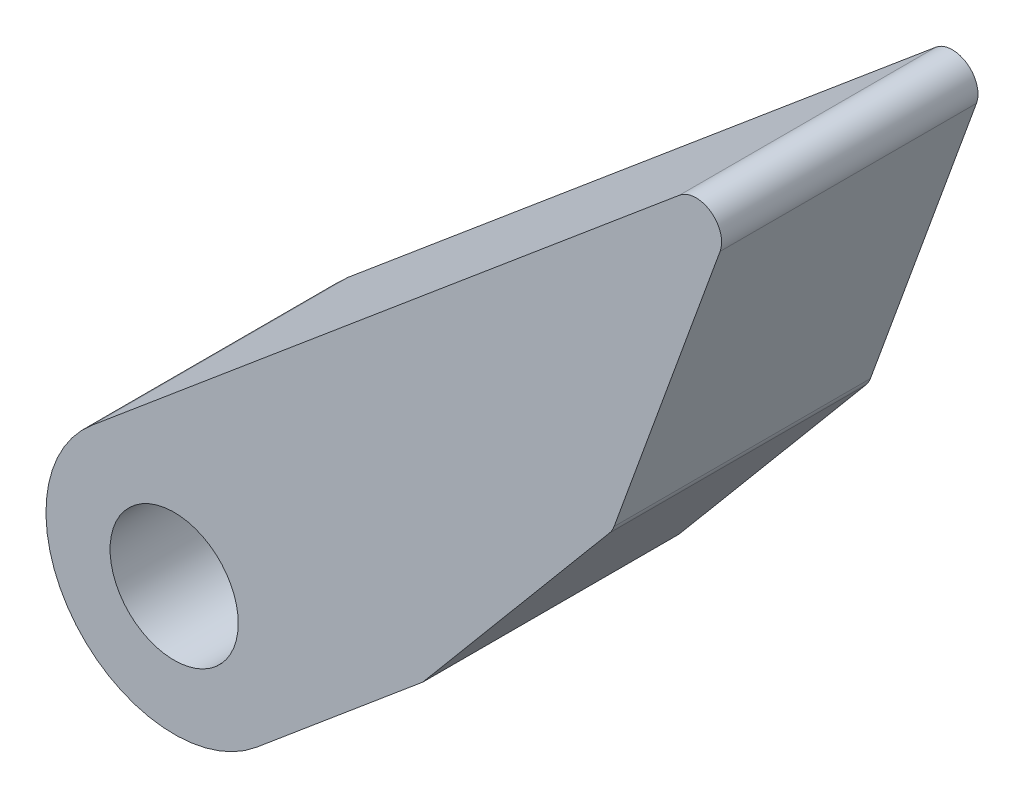
from build123d import *

# Parameters (mm, degrees)
SKETCH_1_R      = 2.5
EXTRUDE_1_DEPTH = 10


with BuildPart() as part:
    # 草圖1 → 填料-伸長1 (new body)
    with BuildSketch(Plane.XY):
        with BuildLine():
            Line((-13.71628672, 4.928383), (-17.851865082, -6.434025166))
            ThreePointArc((-17.851865082, -6.434025166), (-17.925532299, -6.592005023), (-18.02551326, -6.734792632))
            Line((-18.02551326, -6.734792632), (-25.315505088, -15.422666584))
            Line((-25.315505088, -15.422666584), (-31.797224631, -20.861475062))
            ThreePointArc((-31.797224631, -20.861475062), (-35.446941393, -22.012226336), (-38.841384895, -20.245190894))
            ThreePointArc((-38.841384895, -20.245190894), (-39.99213617, -16.595474132), (-38.225100728, -13.20103063))
            Line((-38.225100728, -13.20103063), (-15.298766951, 6.036447586))
            ThreePointArc((-15.298766951, 6.036447586), (-14.082402905, 6.089555187), (-13.71628672, 4.928383))
        make_face()
        with Locations((-35.011162679, -17.031252846)):
            Circle(SKETCH_1_R, mode=Mode.SUBTRACT)
    extrude(amount=EXTRUDE_1_DEPTH)


solid = part.part
